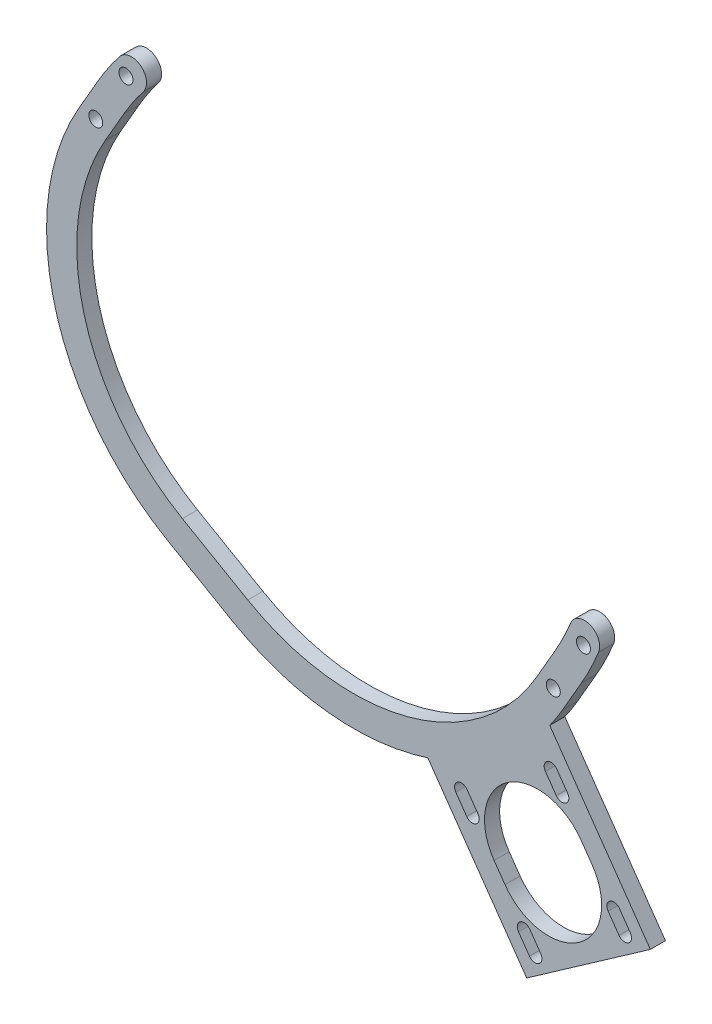
from build123d import *

# Parameters (mm, degrees)
BOSS_EXTRUDE1_DEPTH   = 3.175
BOSS_EXTRUDE2_DEPTH   = 3.175
F_4_CLEARANCE_HOLE1_D = 2.9464


with BuildPart() as part:
    # Sketch1 → Boss-Extrude1 (new body)
    with BuildSketch(Plane(origin=(0, 0, -14.15699402), x_dir=(-1, 0, 0), z_dir=(0, 0, -1))):
        with BuildLine():
            Line((-49.172312317, -34.502108483), (-53.141062317, -27.628031841))
            ThreePointArc((-53.141062317, -27.628031841), (-55.063803638, -24.012221257), (-56.72992661, -20.271224785))
            ThreePointArc((-56.72992661, -20.271224785), (-54.976138042, -16.13776671), (-50.842679967, -17.891555277))
            ThreePointArc((-50.842679967, -17.891555277), (-49.356678398, -21.228119699), (-47.641801003, -24.453031841))
            Line((-47.641801003, -24.453031841), (-43.673051003, -31.327108483))
            ThreePointArc((-43.673051003, -31.327108483), (-16.68272836, -52.037511462), (17.046778195, -47.596937682))
            Line((17.046778195, -47.596937682), (23.920854837, -43.628187682))
            Line((23.920854837, -43.628187682), (30.79493148, -39.659437682))
            ThreePointArc((30.79493148, -39.659437682), (51.505334458, -12.669115038), (47.064760678, 21.060391517))
            Line((47.064760678, 21.060391517), (43.096010678, 27.934468159))
            ThreePointArc((43.096010678, 27.934468159), (41.160593535, 31.032051618), (39.01404477, 33.987248938))
            ThreePointArc((39.01404477, 33.987248938), (39.561948355, 38.44382292), (44.018522337, 37.895919335))
            ThreePointArc((44.018522337, 37.895919335), (46.425258832, 34.58251628), (48.595271992, 31.109468159))
            Line((48.595271992, 31.109468159), (52.564021992, 24.235391517))
            ThreePointArc((52.564021992, 24.235391517), (57.638963455, -14.312615975), (33.96993148, -45.158698996))
            Line((33.96993148, -45.158698996), (27.095854837, -49.127448996))
            Line((27.095854837, -49.127448996), (20.221778195, -53.096198996))
            ThreePointArc((20.221778195, -53.096198996), (-18.326229296, -58.171140459), (-49.172312317, -34.502108483))
        make_face()
    extrude(amount=BOSS_EXTRUDE1_DEPTH)

    # Sketch6 → Boss-Extrude2 (add)
    with BuildSketch(Plane.XY.offset(-14.15699402)):
        Polygon((67.637194266, -68.918706291), (41.629116859, -87.129758146), (18.471608801, -54.057409171), (44.479686207, -35.846357317), align=None)
        with BuildLine():
            Line((53.079900319, -56.321192451), (55.367208432, -59.587806973))
            ThreePointArc((55.367208432, -59.587806973), (52.622655438, -75.152940473), (37.057521938, -72.408387479))
            Line((37.057521938, -72.408387479), (34.770213825, -69.141772956))
            ThreePointArc((34.770213825, -69.141772956), (37.51476682, -53.576639457), (53.079900319, -56.321192451))
        make_face(mode=Mode.SUBTRACT)
        with BuildLine():
            Line((42.200754795, -82.853533634), (39.913446682, -79.586919112))
            ThreePointArc((39.913446682, -79.586919112), (40.268991048, -77.570526818), (42.285383342, -77.926071183))
            Line((42.285383342, -77.926071183), (44.572691455, -81.192685705))
            ThreePointArc((44.572691455, -81.192685705), (44.21714709, -83.209078), (42.200754795, -82.853533634))
        make_face(mode=Mode.SUBTRACT)
        with BuildLine():
            Line((29.086012958, -59.075416679), (31.373321071, -62.342031201))
            ThreePointArc((31.373321071, -62.342031201), (31.017776706, -64.358423496), (29.001384411, -64.00287913))
            Line((29.001384411, -64.00287913), (26.714076299, -60.736264608))
            ThreePointArc((26.714076299, -60.736264608), (27.069620664, -58.719872314), (29.086012958, -59.075416679))
        make_face(mode=Mode.SUBTRACT)
        with BuildLine():
            Line((47.936667462, -45.876046295), (50.223975575, -49.142660817))
            ThreePointArc((50.223975575, -49.142660817), (49.86843121, -51.159053112), (47.852038915, -50.803508747))
            Line((47.852038915, -50.803508747), (45.564730803, -47.536894224))
            ThreePointArc((45.564730803, -47.536894224), (45.920275168, -45.52050193), (47.936667462, -45.876046295))
        make_face(mode=Mode.SUBTRACT)
        with BuildLine():
            Line((61.136037846, -64.726700799), (63.423345959, -67.993315321))
            ThreePointArc((63.423345959, -67.993315321), (63.067801594, -70.009707616), (61.051409299, -69.654163251))
            Line((61.051409299, -69.654163251), (58.764101186, -66.387548728))
            ThreePointArc((58.764101186, -66.387548728), (59.119645552, -64.371156434), (61.136037846, -64.726700799))
        make_face(mode=Mode.SUBTRACT)
    extrude(amount=-BOSS_EXTRUDE2_DEPTH)

    # 4 Clearance Hole1 (through all)
    with Locations(Plane(origin=(0, 0, -17.33199402), x_dir=(-1, 0, 0), z_dir=(0, 0, -1))):
        with Locations((-53.56643166, -20.541270527), (-47.21643166, -31.539793155), (42.670641335, 35.021229473), (49.020641335, 24.022706845)):
            Hole(F_4_CLEARANCE_HOLE1_D / 2)


solid = part.part
